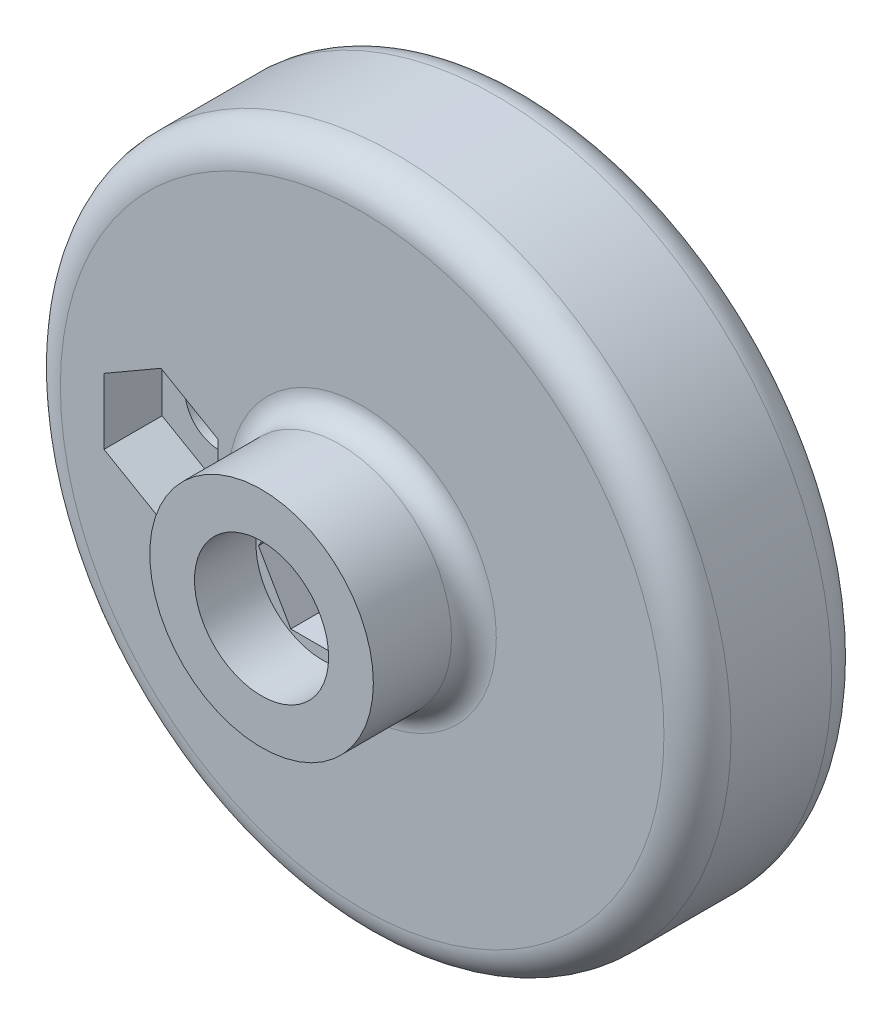
from build123d import *

# Parameters (mm, degrees)
SKETCH1_R           = 30
BOSS_EXTRUDE1_DEPTH = 15
SKETCH2_R           = 10
BOSS_EXTRUDE2_DEPTH = 9
SKETCH3_R           = 3.25
CUT_EXTRUDE1_DEPTH  = 25
FILLET1_R           = 3
SKETCH8_R           = 3.05
CUT_EXTRUDE3_DEPTH  = 16
CUT_EXTRUDE4_DEPTH  = 5.2
SKETCH9_R           = 6
CUT_EXTRUDE5_DEPTH  = 5.5
CUT_EXTRUDE6_DEPTH  = 5.5
FILLET2_R           = 2


with BuildPart() as part:
    # Sketch1 → Boss-Extrude1 (new body)
    with BuildSketch(Plane.XY):
        Circle(SKETCH1_R)
    extrude(amount=BOSS_EXTRUDE1_DEPTH)

    # Sketch2 → Boss-Extrude2 (add)
    with BuildSketch(Plane.XY.offset(15)):
        Circle(SKETCH2_R)
    extrude(amount=BOSS_EXTRUDE2_DEPTH)

    # Sketch3 → Cut-Extrude1 (cut, through all)
    with BuildSketch(Plane.XY.offset(24)):
        Circle(SKETCH3_R)
    extrude(amount=-CUT_EXTRUDE1_DEPTH, mode=Mode.SUBTRACT)

    # Fillet1
    fillet1_edges = [part.edges().sort_by_distance(p)[0] for p in [
        (-3.25, 0, 0),
        (-30, 0, 0),
        (-30, 0, 15),
    ]]
    fillet(fillet1_edges, radius=FILLET1_R)

    # Sketch8 → Cut-Extrude3 (cut, through all)
    with BuildSketch(Plane.XY.offset(15)):
        with Locations((-18, 0)):
            Circle(SKETCH8_R)
    extrude(amount=-CUT_EXTRUDE3_DEPTH, mode=Mode.SUBTRACT)

    # Sketch7 → Cut-Extrude4 (cut)
    with BuildSketch(Plane.XY.offset(15)):
        Polygon((-23.1, 2.944486373), (-23.1, -2.944486373), (-18, -5.888972746), (-12.9, -2.944486373), (-12.9, 2.944486373), (-18, 5.888972746), align=None)
    extrude(amount=-CUT_EXTRUDE4_DEPTH, mode=Mode.SUBTRACT)

    # Sketch9 → Cut-Extrude5 (cut)
    with BuildSketch(Plane.XY.offset(24)):
        Circle(SKETCH9_R)
    extrude(amount=-CUT_EXTRUDE5_DEPTH, mode=Mode.SUBTRACT)

    # Sketch10 → Cut-Extrude6 (cut)
    with BuildSketch(Plane.XY.offset(18.5)):
        Polygon((5.773502692, 0), (2.886751346, 5), (-2.886751346, 5), (-5.773502692, 0), (-2.886751346, -5), (2.886751346, -5), align=None)
    extrude(amount=-CUT_EXTRUDE6_DEPTH, mode=Mode.SUBTRACT)

    # Fillet2
    fillet2_edges = [part.edges().sort_by_distance(p)[0] for p in [
        (-10, 0, 15),
    ]]
    fillet(fillet2_edges, radius=FILLET2_R)


solid = part.part
